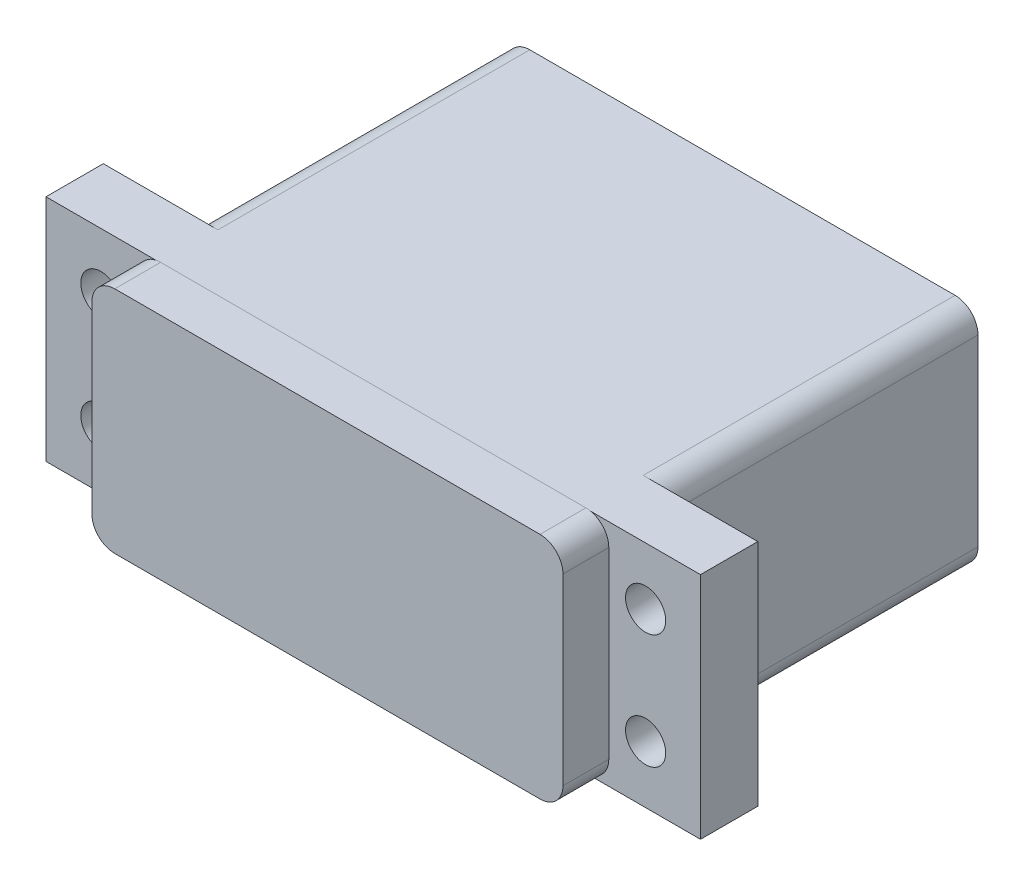
from build123d import *

# Parameters (mm, degrees)
BOSS_EXTRUDE1_DEPTH = 27.21
SKETCH2_W           = 57.1
SKETCH2_H           = 20
BOSS_EXTRUDE2_DEPTH = 5
BOSS_EXTRUDE3_DEPTH = 4
SKETCH4_R           = 1.752596491
CUT_EXTRUDE1_DEPTH  = 5.63


with BuildPart() as part:
    # Sketch1 → Boss-Extrude1 (new body)
    with BuildSketch(Plane.XY):
        with BuildLine():
            Line((9.946325167, -5.324573125), (47.046325167, -5.324573125))
            ThreePointArc((47.046325167, -5.324573125), (48.460538729, -5.910359563), (49.046325167, -7.324573125))
            Line((49.046325167, -7.324573125), (49.046325167, -23.324573125))
            ThreePointArc((49.046325167, -23.324573125), (48.460538729, -24.738786688), (47.046325167, -25.324573125))
            Line((47.046325167, -25.324573125), (9.946325167, -25.324573125))
            ThreePointArc((9.946325167, -25.324573125), (8.532111605, -24.738786688), (7.946325167, -23.324573125))
            Line((7.946325167, -23.324573125), (7.946325167, -7.324573125))
            ThreePointArc((7.946325167, -7.324573125), (8.532111605, -5.910359563), (9.946325167, -5.324573125))
        make_face()
    extrude(amount=BOSS_EXTRUDE1_DEPTH)

    # Sketch2 → Boss-Extrude2 (add)
    with BuildSketch(Plane.XY.offset(27.21)):
        with Locations((28.496325167, -15.324573125)):
            Rectangle(SKETCH2_W, SKETCH2_H)
    extrude(amount=BOSS_EXTRUDE2_DEPTH)

    # Sketch3 → Boss-Extrude3 (add)
    with BuildSketch(Plane.XY.offset(32.21)):
        with BuildLine():
            Line((9.946325167, -5.279301006), (47.046325167, -5.279301006))
            ThreePointArc((47.046325167, -5.279301006), (48.460538729, -5.865087443), (49.046325167, -7.279301006))
            Line((49.046325167, -7.279301006), (49.046325167, -23.279301006))
            ThreePointArc((49.046325167, -23.279301006), (48.460538729, -24.693514568), (47.046325167, -25.279301006))
            Line((47.046325167, -25.279301006), (9.946325167, -25.279301006))
            ThreePointArc((9.946325167, -25.279301006), (8.532111605, -24.693514568), (7.946325167, -23.279301006))
            Line((7.946325167, -23.279301006), (7.946325167, -7.279301006))
            ThreePointArc((7.946325167, -7.279301006), (8.532111605, -5.865087443), (9.946325167, -5.279301006))
        make_face()
    extrude(amount=BOSS_EXTRUDE3_DEPTH)

    # Sketch4 → Cut-Extrude1 (cut)
    with BuildSketch(Plane.XY.offset(32.21)):
        with Locations((4.734760216, -10.324573125)):
            Circle(SKETCH4_R)
        with Locations((4.734760216, -20.324573125)):
            Circle(SKETCH4_R)
        with Locations((52.257890118, -20.324573125)):
            Circle(SKETCH4_R)
        with Locations((52.257890118, -10.324573125)):
            Circle(SKETCH4_R)
    extrude(amount=-CUT_EXTRUDE1_DEPTH, mode=Mode.SUBTRACT)


solid = part.part
